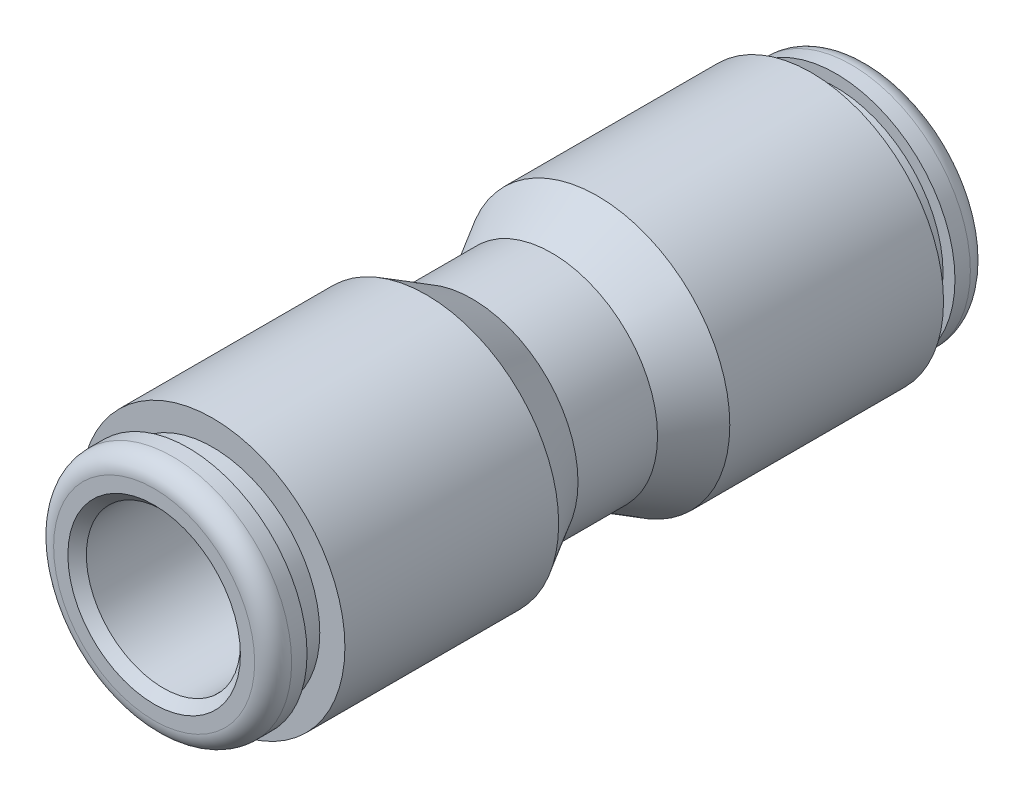
from build123d import *


with BuildPart() as part:
    # Sketch1 → Revolve1 (revolve)
    with BuildSketch(Plane(origin=(0, 0, 0), x_dir=(0, 0, -1), z_dir=(1, 0, 0))):
        with BuildLine():
            Line((13.353, 4.905), (13.988, 4.905))
            ThreePointArc((13.988, 4.905), (14.526815367, 4.681815367), (14.75, 4.143))
            Line((14.75, 4.143), (14.75, 3.556))
            Line((14.75, 3.556), (14.369, 3.175))
            Line((14.369, 3.175), (0.25, 3.175))
            Line((0.25, 3.175), (0.25, 2.413))
            Line((0.25, 2.413), (0, 2.413))
            Line((0, 2.413), (0, 4.36))
            Line((0, 4.36), (1.638888889, 4.36))
            Line((1.638888889, 4.36), (3.526824269, 5.45))
            Line((3.526824269, 5.45), (12.337, 5.45))
            Line((12.337, 5.45), (12.337, 4.4145))
            Line((12.337, 4.4145), (13.353, 4.4145))
            Line((13.353, 4.4145), (13.353, 4.905))
        make_face()
    revolve1 = revolve(axis=Axis((0, 0, 0), (0, 0, -1)))

    # Mirror1: Revolve1 across plane
    add(revolve1.mirror(Plane.XY))


solid = part.part
